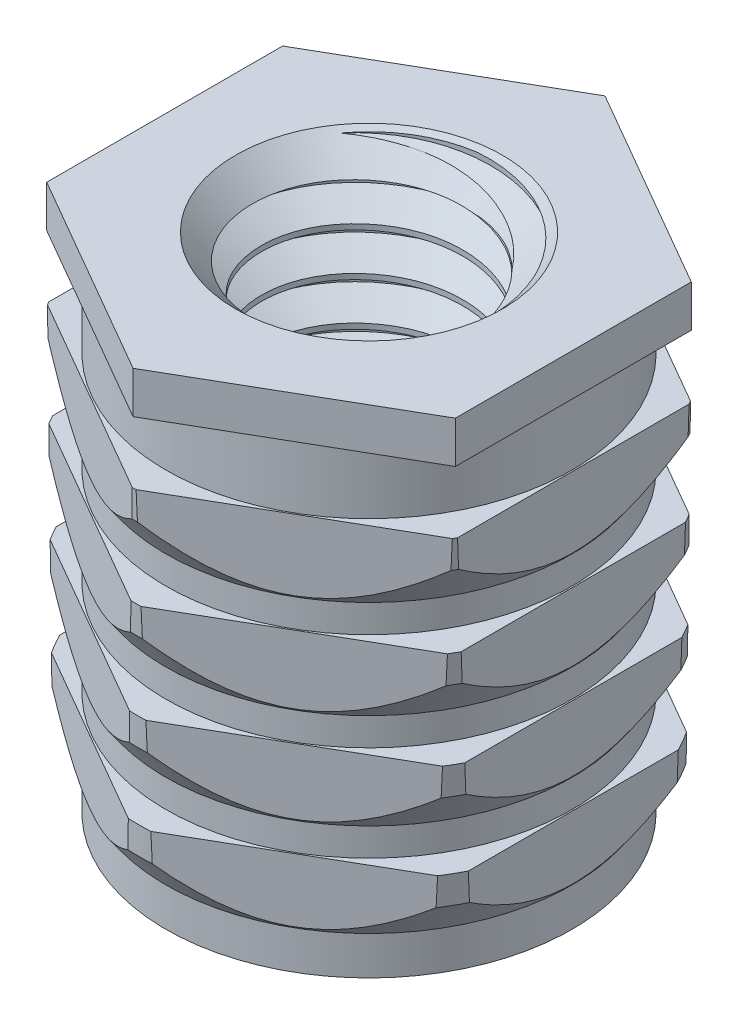
from build123d import *

# Parameters (mm, degrees)
EXTRUDE1_DEPTH         = 5.84
SKETCH4_R              = 1.175240473580836
EXTRUDE2_DEPTH         = 7.875104241633964
CHAMFER1_SIZE          = 0.375
CUT_SWEEP1_PITCH       = 0.49999999999999556
CUT_SWEEP1_HEIGHT      = 6.8780999999999795
CUT_SWEEP1_RADIUS      = 1.5000000000000002
CUT_SWEEP1_START_ANGLE = -90.00000000000055


with BuildPart() as part:
    # Sketch1 → Extrude1 (new body)
    with BuildSketch(Plane(origin=(0, 0, 0), x_dir=(1, 0, 0), z_dir=(0, 1, 0))):
        Polygon((0, 2.7424137786507212), (-2.3750000000000004, 1.3712068893253624), (-2.3749999999999996, -1.3712068893253624), (3.3e-16, -2.742413778650722), (2.3750000000000004, -1.3712068893253624), (2.3749999999999996, 1.371206889325362), align=None)
    extrude(amount=-EXTRUDE1_DEPTH)

    # Sketch4 → Extrude2 (cut, through all)
    with BuildSketch(Plane(origin=(0, 0, 0), x_dir=(-1, 0, 0), z_dir=(0, 1, 0))):
        with Locations(Location((0, 0, 0), (0, 0, 90))):
            Circle(SKETCH4_R)
    extrude(amount=-EXTRUDE2_DEPTH, mode=Mode.SUBTRACT)

    # Chamfer1
    chamfer1_edges = [part.edges().sort_by_distance(p)[0] for p in [
        (2.2e-16, -5.84, -1.175240473580836),
        (2.2e-16, 0, -1.175240473580836),
    ]]
    chamfer(chamfer1_edges, length=CHAMFER1_SIZE)

    # Cut-Sweep1: sweep along a helix
    with BuildLine() as cut_sweep1_path:
        add(Helix(CUT_SWEEP1_PITCH, CUT_SWEEP1_HEIGHT, CUT_SWEEP1_RADIUS, center=(0, 0, 0), direction=(0, -1, 0), mode=Mode.PRIVATE).rotate(Axis((0, 0, 0), (0, -1, 0)), CUT_SWEEP1_START_ANGLE))
    with BuildLine() as cut_sweep1_axis:
        Line((0, 0, 0), (0, -6.8780999999999795, 0))
    # Sketch3 → Cut-Sweep1 (sweep, cut)
    with BuildSketch(Plane.XY):
        Polygon((-1.5, 0.06249999999999994), (-1.5, 0), (-1.1481771797125722, -0.2031249999999996), (-1.1481771797125722, 0.26562499999999967), align=None)
    sweep(path=cut_sweep1_path.line, binormal=cut_sweep1_axis.edges()[0], mode=Mode.SUBTRACT)

    # Sketch5 → Cut-Revolve1 (revolve, cut)
    with BuildSketch(Plane.XY):
        Polygon((-2.3600000000000003, -5.84), (-2.7424137786507212, -5.84), (-3.1248275573014412, -5.84), (-3.1248275573014426, 7e-17), (-2.7424137786507212, 0), (-2.7424137786507212, -0.48666666666666664), (-2.36, -0.4866666666666666), (-2.36, -1.2166666666666668), (-2.7296715812531254, -1.2166666666666668), (-2.724015418050607, -1.5407080395162458), (-2.36, -2.060575933228616), (-2.3600000000000003, -2.3846666666666665), (-2.70928406541697, -2.384666666666666), (-2.7036279022144516, -2.708708039516245), (-2.3600000000000003, -3.199459543124787), (-2.3600000000000003, -3.5235502765628373), (-2.6894047780605517, -3.5235502765628364), (-2.6837486148580343, -3.8475916494124154), (-2.3600000000000003, -4.3099525884074374), (-2.3600000000000003, -4.634043321845487), (-2.670021049852811, -4.634043321845487), (-2.6643648866502927, -4.958084694695066), (-2.3600000000000003, -5.39276280088697), align=None)
    revolve(axis=Axis((8.3e-16, 0, 0), (-9e-17, -1, 0)), mode=Mode.SUBTRACT)


solid = part.part
